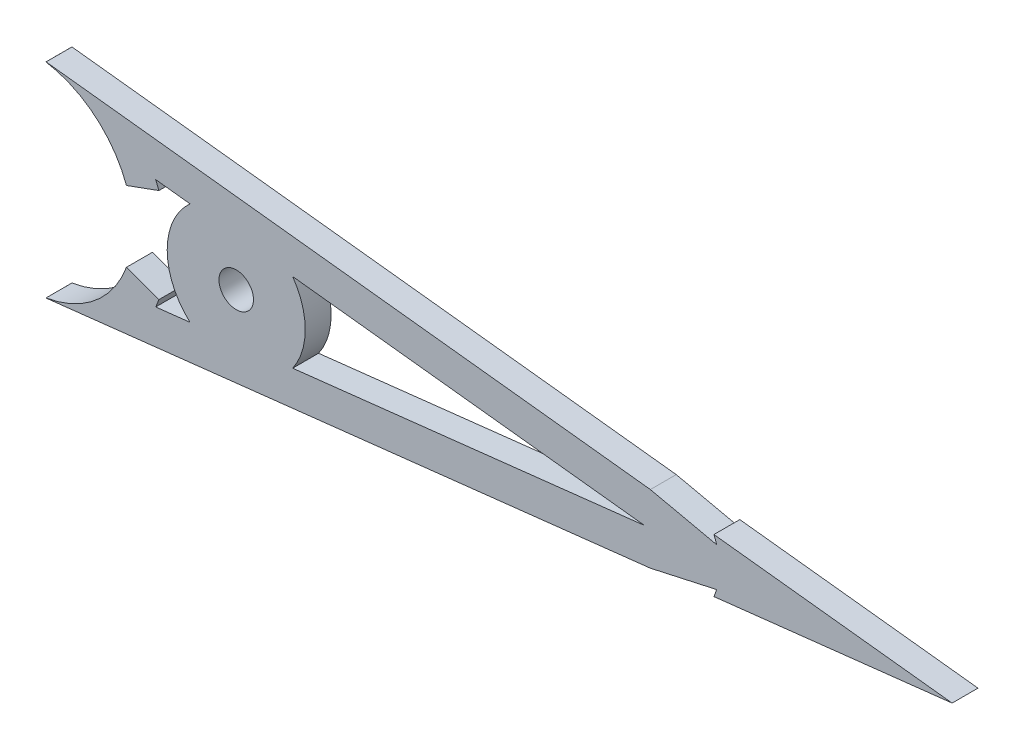
from build123d import *

# Parameters (mm, degrees)
SKETCH1_R           = 3.175
BOSS_EXTRUDE2_DEPTH = 4.7625
FILLET1_R           = 0.0127


with BuildPart() as part:
    # Sketch1 → Boss-Extrude2 (new body)
    with BuildSketch(Plane.XY):
        with BuildLine():
            Line((131.7244, 0), (87.896637, 4.947593))
            ThreePointArc((87.896637, 4.947593), (88.160392, 4.270718), (88.385012, 3.579871))
            Line((88.385012, 3.579871), (76.2, 6.267993))
            Line((76.2, 6.267993), (-35.963072, 18.929766))
            ThreePointArc((-35.963072, 18.929766), (-26.314005, 14.966389), (-20.198856, 6.515484))
            Line((-20.198856, 6.515484), (-14.231807, 8.687312))
            ThreePointArc((-14.231807, 8.687312), (-14.513112, 9.424368), (-14.81717, 10.152332))
            Line((-14.81717, 10.152332), (-8.496937, 9.438859))
            ThreePointArc((-8.496937, 9.438859), (-12.7, 0), (-8.496937, -9.438859))
            Line((-8.496937, -9.438859), (-14.81717, -10.152332))
            ThreePointArc((-14.81717, -10.152332), (-14.513112, -9.424368), (-14.231807, -8.687312))
            Line((-14.231807, -8.687312), (-20.198856, -6.515484))
            ThreePointArc((-20.198856, -6.515484), (-26.314005, -14.966389), (-35.963072, -18.929766))
            Line((-35.963072, -18.929766), (76.2, -6.267993))
            Line((76.2, -6.267993), (88.385012, -3.579871))
            ThreePointArc((88.385012, -3.579871), (88.160392, -4.270718), (87.896637, -4.947593))
            Line((87.896637, -4.947593), (131.7244, 0))
        make_face()
        Circle(SKETCH1_R, mode=Mode.SUBTRACT)
        with BuildLine():
            Line((75.116267, 0), (10.387338, 7.307066))
            ThreePointArc((10.387338, 7.307066), (12.7, 0), (10.387338, -7.307066))
            Line((10.387338, -7.307066), (75.116267, 0))
        make_face(mode=Mode.SUBTRACT)
    extrude(amount=-BOSS_EXTRUDE2_DEPTH)

    # Fillet1
    fillet1_edges = [part.edges().sort_by_distance(p)[0] for p in [
        (-35.963072, 18.929766, -2.38125),
        (-35.963072, -18.929766, -2.38125),
    ]]
    fillet(fillet1_edges, radius=FILLET1_R)


solid = part.part
